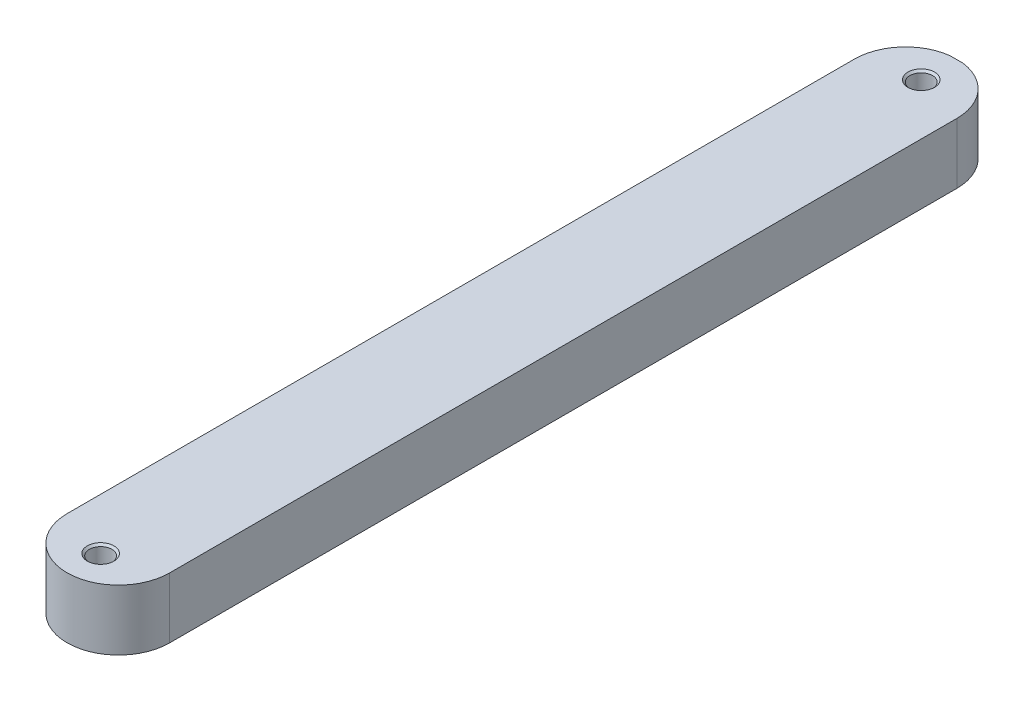
from build123d import *

# Parameters (mm, degrees)
SKETCH_1_W                      = 200
SKETCH_1_H                      = 20
EXTRUDE_1_DEPTH                 = 30
SKETCH_3_W                      = 30
SKETCH_3_H                      = 17.724954358
EXTRUDE_2_DEPTH                 = 30
EXTRUDE_2_DEPTH_BACK            = 1
CUT_EXTRUDE_1_DEPTH             = 18
HOLE_WIZARD_G1_16_1_D           = 6.6
HOLE_WIZARD_G1_16_1_DEPTH       = 17.724954357
HOLE_WIZARD_G1_16_1_CSINK_D     = 7.773
HOLE_WIZARD_G1_16_1_CSINK_ANGLE = 90
SKETCH_9_W                      = 30
SKETCH_9_H                      = 17.724954358
EXTRUDE_3_DEPTH                 = 30
CUT_EXTRUDE_2_DEPTH             = 30
HOLE_WIZARD_G1_16_2_D           = 6.6
HOLE_WIZARD_G1_16_2_DEPTH       = 17.724954357
HOLE_WIZARD_G1_16_2_CSINK_D     = 7.773
HOLE_WIZARD_G1_16_2_CSINK_ANGLE = 90
SKETCH_14_W                     = 30
SKETCH_14_H                     = 1.0813423
SKETCH_14_H_2                   = 1.193703342
CUT_EXTRUDE_3_DEPTH             = 215


with BuildPart() as part:
    # 草图1 → 凸台-拉伸1 (new body)
    with BuildSketch(Plane(origin=(0, 0, 0), x_dir=(0, 0, -1), z_dir=(1, 0, 0))):
        with Locations((100, -10)):
            Rectangle(SKETCH_1_W, SKETCH_1_H)
    extrude(amount=EXTRUDE_1_DEPTH)

    # 草图3 → 凸台-拉伸2 (add, two sides)
    with BuildSketch(Plane.XY) as extrude_2_sk:
        with Locations((15, -9.943819479)):
            Rectangle(SKETCH_3_W, SKETCH_3_H)
    extrude(amount=EXTRUDE_2_DEPTH)
    extrude(extrude_2_sk.sketch, amount=-EXTRUDE_2_DEPTH_BACK)

    # 草图5 → 切除-拉伸1 (cut)
    with BuildSketch(Plane(origin=(0, -1.0813423, 0), x_dir=(1, 0, 0), z_dir=(0, 1, 0))):
        with BuildLine():
            ThreePointArc((15, -30), (4.393398282, -25.606601718), (0, -15))
            Line((0, -15), (0, -30))
            Line((0, -30), (15, -30))
        make_face()
        with BuildLine():
            Line((30, -30), (30, -15))
            ThreePointArc((30, -15), (25.606601718, -25.606601718), (15, -30))
            Line((15, -30), (30, -30))
        make_face()
    extrude(amount=-CUT_EXTRUDE_1_DEPTH, mode=Mode.SUBTRACT)

    # G1/16 螺纹孔1
    with Locations(Plane(origin=(0, -1.0813423, 0), x_dir=(1, 0, 0), z_dir=(0, 1, 0))):
        with Locations((15, -20.203891656)):
            CounterSinkHole(HOLE_WIZARD_G1_16_1_D / 2, HOLE_WIZARD_G1_16_1_CSINK_D / 2, depth=HOLE_WIZARD_G1_16_1_DEPTH, counter_sink_angle=HOLE_WIZARD_G1_16_1_CSINK_ANGLE)

    # 草图9 → 凸台-拉伸3 (add)
    with BuildSketch(Plane(origin=(0, 0, -200), x_dir=(-1, 0, 0), z_dir=(0, 0, -1))):
        with Locations((-15, -9.943819479)):
            Rectangle(SKETCH_9_W, SKETCH_9_H)
    extrude(amount=EXTRUDE_3_DEPTH)

    # 草图10 → 切除-拉伸2 (cut)
    with BuildSketch(Plane(origin=(0, -1.0813423, 0), x_dir=(1, 0, 0), z_dir=(0, 1, 0))):
        with BuildLine():
            Line((0, 230), (0, 215.122561862))
            ThreePointArc((0, 215.122561862), (3.737143337, 225.029532125), (13.086407972, 230))
            Line((13.086407972, 230), (0, 230))
        make_face()
        with BuildLine():
            ThreePointArc((16.913592028, 230), (26.262856663, 225.029532125), (30, 215.122561862))
            Line((30, 215.122561862), (30, 230))
            Line((30, 230), (16.913592028, 230))
        make_face()
    extrude(amount=-CUT_EXTRUDE_2_DEPTH, mode=Mode.SUBTRACT)

    # G1/16 螺纹孔2
    with Locations(Plane(origin=(0, -1.0813423, 0), x_dir=(1, 0, 0), z_dir=(0, 1, 0))):
        with Locations((15, 219.701584922)):
            CounterSinkHole(HOLE_WIZARD_G1_16_2_D / 2, HOLE_WIZARD_G1_16_2_CSINK_D / 2, depth=HOLE_WIZARD_G1_16_2_DEPTH, counter_sink_angle=HOLE_WIZARD_G1_16_2_CSINK_ANGLE)

    # 草图14 → 切除-拉伸3 (cut)
    with BuildSketch(Plane.XY):
        with Locations((15, -0.54067115)):
            Rectangle(SKETCH_14_W, SKETCH_14_H)
        with Locations((15, -19.403148329)):
            Rectangle(SKETCH_14_W, SKETCH_14_H_2)
    extrude(amount=-CUT_EXTRUDE_3_DEPTH, mode=Mode.SUBTRACT)


solid = part.part
